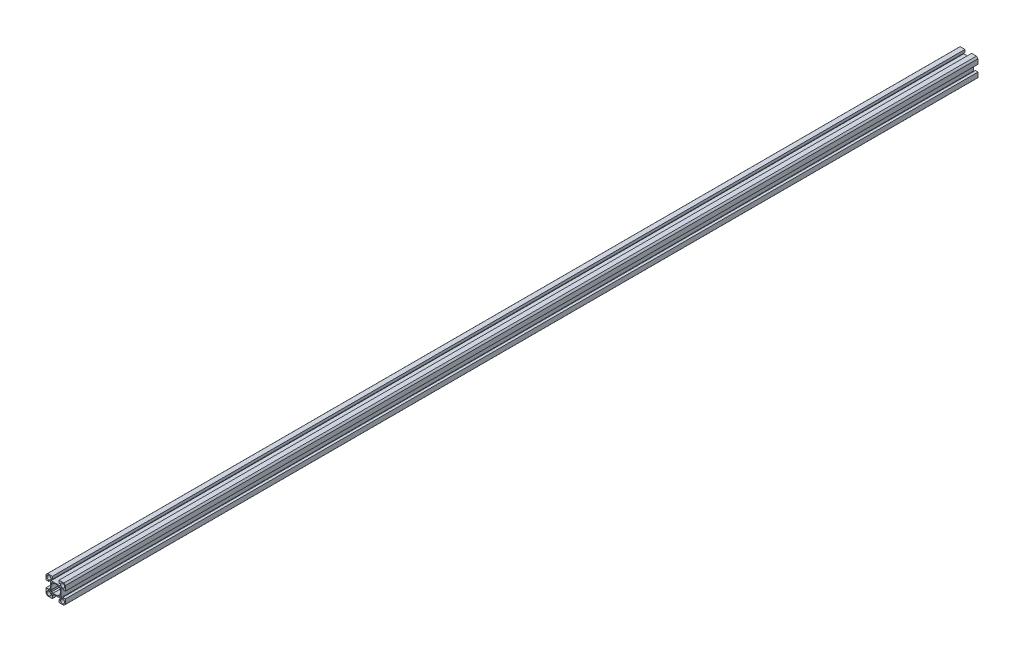
from build123d import *

# Parameters (mm, degrees)
SKETCH3_R           = 2.032
SKETCH3_W           = 0.76159928
SKETCH3_H           = 0.76159928
SKETCH3_W_2         = 1.204804675
SKETCH3_H_2         = 2.605195325
SKETCH3_W_3         = 2.605195325
SKETCH3_H_3         = 1.204804675
BOSS_EXTRUDE3_DEPTH = 914.4


with BuildPart() as part:
    # Sketch3 → Boss-Extrude3 (new body)
    with BuildSketch(Plane.XY):
        with BuildLine():
            ThreePointArc((9.717596045, 8.176694142), (8.980256121, 8.980256121), (8.176694142, 9.717596045))
            Line((8.176694142, 9.717596045), (4.57240072, 9.717596045))
            Line((4.57240072, 9.717596045), (4.57240072, 7.11240072))
            Line((4.57240072, 7.11240072), (4.57240072, 5.334))
            Line((4.57240072, 5.334), (5.334, 5.334))
            Line((5.334, 5.334), (5.334, 4.57240072))
            Line((5.334, 4.57240072), (7.11240072, 4.57240072))
            Line((7.11240072, 4.57240072), (9.717596045, 4.57240072))
            Line((9.717596045, 4.57240072), (9.717596045, 8.176694142))
        make_face()
        with Locations((6.914797213, 6.914797213)):
            Circle(SKETCH3_R, mode=Mode.SUBTRACT)
        with Locations((4.95320036, 4.95320036)):
            Rectangle(SKETCH3_W, SKETCH3_H)
        Polygon((4.57240072, 5.334), (3.367596045, 5.334), (3.367596045, 4.191), (4.191, 4.191), (4.191, 3.367596045), (5.334, 3.367596045), (5.334, 4.57240072), (4.57240072, 4.57240072), align=None)
        with BuildLine():
            Line((3.367596045, 5.334), (-3.367596045, 5.334))
            Line((-3.367596045, 5.334), (-3.367596045, 4.191))
            Line((-3.367596045, 4.191), (-2.262062168, 4.191))
            ThreePointArc((-2.262062168, 4.191), (0, 4.7625), (2.262062168, 4.191))
            Line((2.262062168, 4.191), (3.367596045, 4.191))
            Line((3.367596045, 4.191), (3.367596045, 5.334))
        make_face()
        with BuildLine():
            Line((5.334, 3.367596045), (4.191, 3.367596045))
            Line((4.191, 3.367596045), (4.191, 2.262062168))
            ThreePointArc((4.191, 2.262062168), (4.617415064, 1.16656949), (4.7625, 0))
            ThreePointArc((4.7625, 0), (4.617415064, -1.16656949), (4.191, -2.262062168))
            Line((4.191, -2.262062168), (4.191, -3.367596045))
            Line((4.191, -3.367596045), (5.334, -3.367596045))
            Line((5.334, -3.367596045), (5.334, 3.367596045))
        make_face()
        with Locations((3.969998383, 8.414998383)):
            Rectangle(SKETCH3_W_2, SKETCH3_H_2)
        with Locations((8.414998383, 3.969998383)):
            Rectangle(SKETCH3_W_3, SKETCH3_H_3)
        with BuildLine():
            Line((4.57240072, -9.717596045), (8.176694142, -9.717596045))
            ThreePointArc((8.176694142, -9.717596045), (8.980256121, -8.980256121), (9.717596045, -8.176694142))
            Line((9.717596045, -8.176694142), (9.717596045, -4.57240072))
            Line((9.717596045, -4.57240072), (7.11240072, -4.57240072))
            Line((7.11240072, -4.57240072), (5.334, -4.57240072))
            Line((5.334, -4.57240072), (5.334, -5.334))
            Line((5.334, -5.334), (4.57240072, -5.334))
            Line((4.57240072, -5.334), (4.57240072, -7.11240072))
            Line((4.57240072, -7.11240072), (4.57240072, -9.717596045))
        make_face()
        with Locations((6.914797213, -6.914797213)):
            Circle(SKETCH3_R, mode=Mode.SUBTRACT)
        with Locations((4.95320036, -4.95320036)):
            Rectangle(SKETCH3_W, SKETCH3_H)
        with Locations((8.414998383, -3.969998383)):
            Rectangle(SKETCH3_W_3, SKETCH3_H_3)
        with Locations((3.969998383, -8.414998383)):
            Rectangle(SKETCH3_W_2, SKETCH3_H_2)
        Polygon((3.367596045, -4.191), (3.367596045, -5.334), (4.57240072, -5.334), (4.57240072, -4.57240072), (5.334, -4.57240072), (5.334, -3.367596045), (4.191, -3.367596045), (4.191, -4.191), align=None)
        with BuildLine():
            Line((-2.262062168, -4.191), (-3.367596045, -4.191))
            Line((-3.367596045, -4.191), (-3.367596045, -5.334))
            Line((-3.367596045, -5.334), (3.367596045, -5.334))
            Line((3.367596045, -5.334), (3.367596045, -4.191))
            Line((3.367596045, -4.191), (2.262062168, -4.191))
            ThreePointArc((2.262062168, -4.191), (0, -4.7625), (-2.262062168, -4.191))
        make_face()
        with Locations((-4.95320036, -4.95320036)):
            Rectangle(SKETCH3_W, SKETCH3_H)
        Polygon((-4.191, -3.367596045), (-5.334, -3.367596045), (-5.334, -4.57240072), (-4.57240072, -4.57240072), (-4.57240072, -5.334), (-3.367596045, -5.334), (-3.367596045, -4.191), (-4.191, -4.191), align=None)
        with BuildLine():
            Line((-5.334, -4.57240072), (-7.11240072, -4.57240072))
            Line((-7.11240072, -4.57240072), (-9.717596045, -4.57240072))
            Line((-9.717596045, -4.57240072), (-9.717596045, -8.176694142))
            ThreePointArc((-9.717596045, -8.176694142), (-8.980256121, -8.980256121), (-8.176694142, -9.717596045))
            Line((-8.176694142, -9.717596045), (-4.57240072, -9.717596045))
            Line((-4.57240072, -9.717596045), (-4.57240072, -7.11240072))
            Line((-4.57240072, -7.11240072), (-4.57240072, -5.334))
            Line((-4.57240072, -5.334), (-5.334, -5.334))
            Line((-5.334, -5.334), (-5.334, -4.57240072))
        make_face()
        with Locations((-6.914797213, -6.914797213)):
            Circle(SKETCH3_R, mode=Mode.SUBTRACT)
        with Locations((-3.969998383, -8.414998383)):
            Rectangle(SKETCH3_W_2, SKETCH3_H_2)
        with Locations((-8.414998383, -3.969998383)):
            Rectangle(SKETCH3_W_3, SKETCH3_H_3)
        with BuildLine():
            Line((-4.191, 3.367596045), (-5.334, 3.367596045))
            Line((-5.334, 3.367596045), (-5.334, -3.367596045))
            Line((-5.334, -3.367596045), (-4.191, -3.367596045))
            Line((-4.191, -3.367596045), (-4.191, -2.262062168))
            ThreePointArc((-4.191, -2.262062168), (-4.7625, 0), (-4.191, 2.262062168))
            Line((-4.191, 2.262062168), (-4.191, 3.367596045))
        make_face()
        with Locations((-4.95320036, 4.95320036)):
            Rectangle(SKETCH3_W, SKETCH3_H)
        Polygon((-4.57240072, 4.57240072), (-5.334, 4.57240072), (-5.334, 3.367596045), (-4.191, 3.367596045), (-4.191, 4.191), (-3.367596045, 4.191), (-3.367596045, 5.334), (-4.57240072, 5.334), align=None)
        with BuildLine():
            Line((-9.717596045, 4.57240072), (-7.11240072, 4.57240072))
            Line((-7.11240072, 4.57240072), (-5.334, 4.57240072))
            Line((-5.334, 4.57240072), (-5.334, 5.334))
            Line((-5.334, 5.334), (-4.57240072, 5.334))
            Line((-4.57240072, 5.334), (-4.57240072, 7.11240072))
            Line((-4.57240072, 7.11240072), (-4.57240072, 9.717596045))
            Line((-4.57240072, 9.717596045), (-8.176694142, 9.717596045))
            ThreePointArc((-8.176694142, 9.717596045), (-8.980256121, 8.980256121), (-9.717596045, 8.176694142))
            Line((-9.717596045, 8.176694142), (-9.717596045, 4.57240072))
        make_face()
        with Locations((-6.914797213, 6.914797213)):
            Circle(SKETCH3_R, mode=Mode.SUBTRACT)
        with Locations((-3.969998383, 8.414998383)):
            Rectangle(SKETCH3_W_2, SKETCH3_H_2)
        with Locations((-8.414998383, 3.969998383)):
            Rectangle(SKETCH3_W_3, SKETCH3_H_3)
    extrude(amount=BOSS_EXTRUDE3_DEPTH)


solid = part.part
